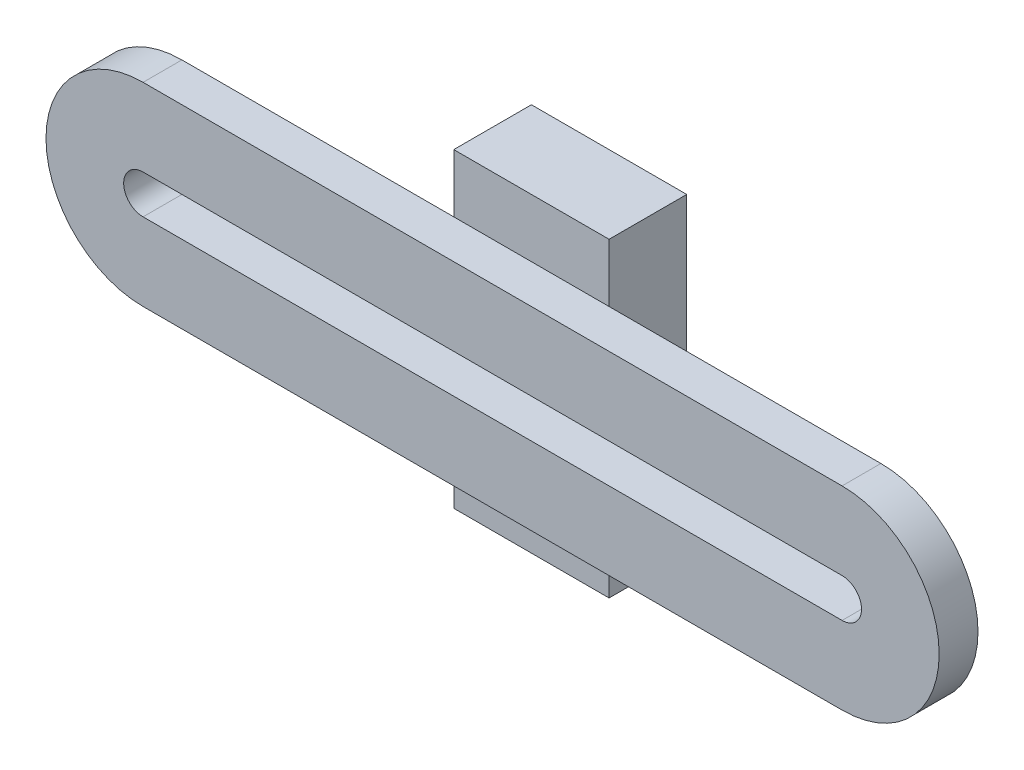
from build123d import *

# Parameters (mm, degrees)
SKETCH2_W           = 25.4
SKETCH2_H           = 50.8
SKETCH2_R           = 6.35
BOSS_EXTRUDE1_DEPTH = 12.7
BOSS_EXTRUDE2_DEPTH = 6.35


with BuildPart() as part:
    # Sketch2 → Boss-Extrude1 (new body)
    with BuildSketch(Plane.XY):
        with Locations((0, -61.205719116)):
            Rectangle(SKETCH2_W, SKETCH2_H)
        with Locations((0, -61.205719116)):
            Circle(SKETCH2_R, mode=Mode.SUBTRACT)
    extrude(amount=-BOSS_EXTRUDE1_DEPTH)

    # Sketch3 → Boss-Extrude2 (add)
    with BuildSketch(Plane.XY):
        with BuildLine():
            Line((-57.15, -45.330719116), (57.15, -45.330719116))
            ThreePointArc((57.15, -45.330719116), (73.025, -61.205719116), (57.15, -77.080719116))
            Line((57.15, -77.080719116), (-57.15, -77.080719116))
            ThreePointArc((-57.15, -77.080719116), (-73.025, -61.205719116), (-57.15, -45.330719116))
        make_face()
        with BuildLine():
            Line((-57.15, -58.030719116), (57.15, -58.030719116))
            ThreePointArc((57.15, -58.030719116), (60.325, -61.205719116), (57.15, -64.380719116))
            Line((57.15, -64.380719116), (-57.15, -64.380719116))
            ThreePointArc((-57.15, -64.380719116), (-60.325, -61.205719116), (-57.15, -58.030719116))
        make_face(mode=Mode.SUBTRACT)
    extrude(amount=BOSS_EXTRUDE2_DEPTH)


solid = part.part
